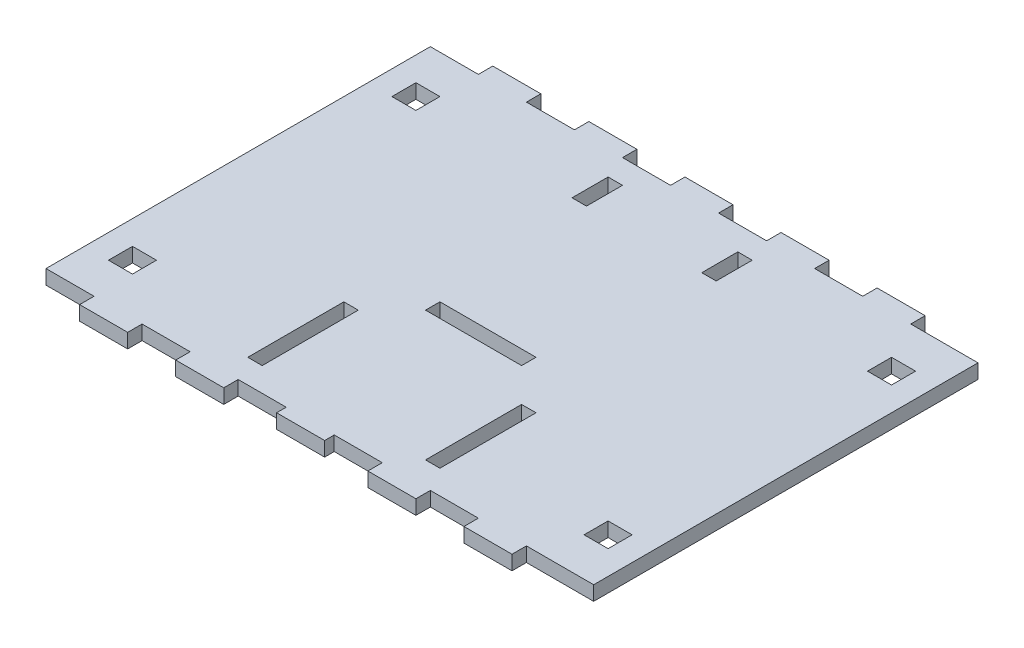
from build123d import *

# Parameters (mm, degrees)
BOSS_EXTRUDE1_DEPTH = 6
SKETCH2_W           = 10
SKETCH2_H           = 10
CUT_EXTRUDE1_DEPTH  = 6
SKETCH4_W           = 40
SKETCH4_H           = 6
SKETCH4_W_2         = 6
SKETCH4_H_2         = 40
SKETCH4_H_3         = 15
CUT_EXTRUDE2_DEPTH  = 6


with BuildPart() as part:
    # Sketch1 → Boss-Extrude1 (new body)
    with BuildSketch(Plane(origin=(0, 0, 0), x_dir=(1, 0, 0), z_dir=(0, 1, 0))):
        Polygon((-94, 86), (-74, 86), (-74, 80), (-54, 80), (-54, 86), (-34, 86), (-34, 80), (-14, 80), (-14, 86), (6, 86), (6, 80), (26, 80), (26, 86), (46, 86), (46, 80), (66, 80), (66, 86), (86, 86), (86, 80), (114, 80), (114, -80), (86, -80), (86, -86), (66, -86), (66, -80), (46, -80), (46, -86), (26, -86), (26, -80), (6, -80), (6, -86), (-14, -86), (-14, -80), (-34, -80), (-34, -86), (-54, -86), (-54, -80), (-74, -80), (-74, -86), (-94, -86), (-94, -80), (-114, -80), (-114, 80), (-94, 80), align=None)
    extrude(amount=BOSS_EXTRUDE1_DEPTH)

    # Sketch2 → Cut-Extrude1 (cut)
    with BuildSketch(Plane(origin=(0, 0, 0), x_dir=(1, 0, 0), z_dir=(0, 1, 0))):
        with Locations((-99, 59)):
            Rectangle(SKETCH2_W, SKETCH2_H)
        with Locations((99, 59)):
            Rectangle(SKETCH2_W, SKETCH2_H)
        with Locations((99, -59)):
            Rectangle(SKETCH2_W, SKETCH2_H)
        with Locations((-99, -59)):
            Rectangle(SKETCH2_W, SKETCH2_H)
    extrude(amount=CUT_EXTRUDE1_DEPTH, mode=Mode.SUBTRACT)

    # Sketch4 → Cut-Extrude2 (cut)
    with BuildSketch(Plane(origin=(0, 6, 0), x_dir=(1, 0, 0), z_dir=(0, 1, 0))):
        with Locations((0, -13)):
            Rectangle(SKETCH4_W, SKETCH4_H)
        with Locations((0, -87)):
            Rectangle(SKETCH4_W, SKETCH4_H)
        with Locations((-37, -50)):
            Rectangle(SKETCH4_W_2, SKETCH4_H_2)
        with Locations((37, -50)):
            Rectangle(SKETCH4_W_2, SKETCH4_H_2)
        with Locations((-27, 62.5)):
            Rectangle(SKETCH4_W_2, SKETCH4_H_3)
        with Locations((27, 62.5)):
            Rectangle(SKETCH4_W_2, SKETCH4_H_3)
    extrude(amount=-CUT_EXTRUDE2_DEPTH, mode=Mode.SUBTRACT)


solid = part.part
